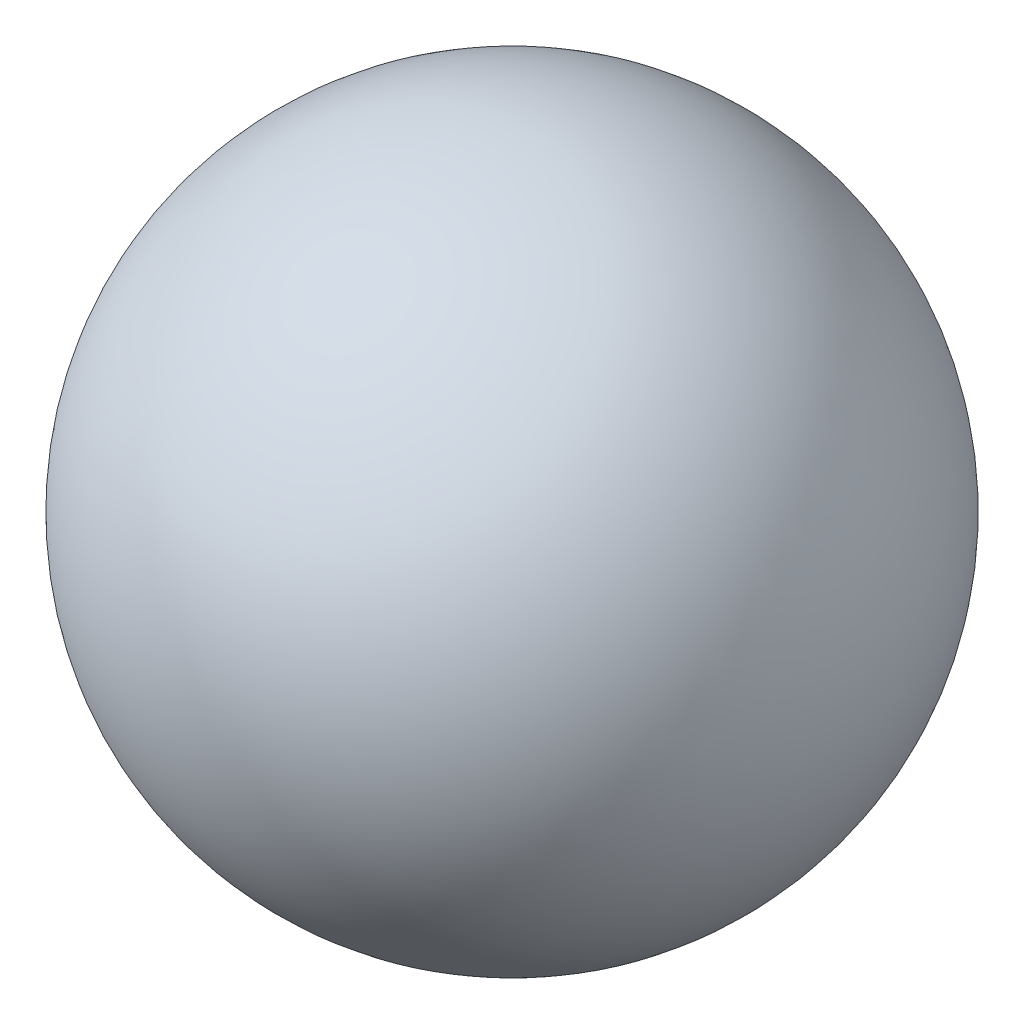
from build123d import *


with BuildPart() as part:
    # Sketch1 → Revolve1 (revolve)
    with BuildSketch(Plane(origin=(0, 0, 0), x_dir=(0, 0, -1), z_dir=(1, 0, 0))):
        with BuildLine():
            Line((0, -12.7), (0, 12.7))
            ThreePointArc((0, 12.7), (12.7, 0), (0, -12.7))
        make_face()
    revolve(axis=Axis((0, -12.7, 0), (0, 1, 0)))


solid = part.part
